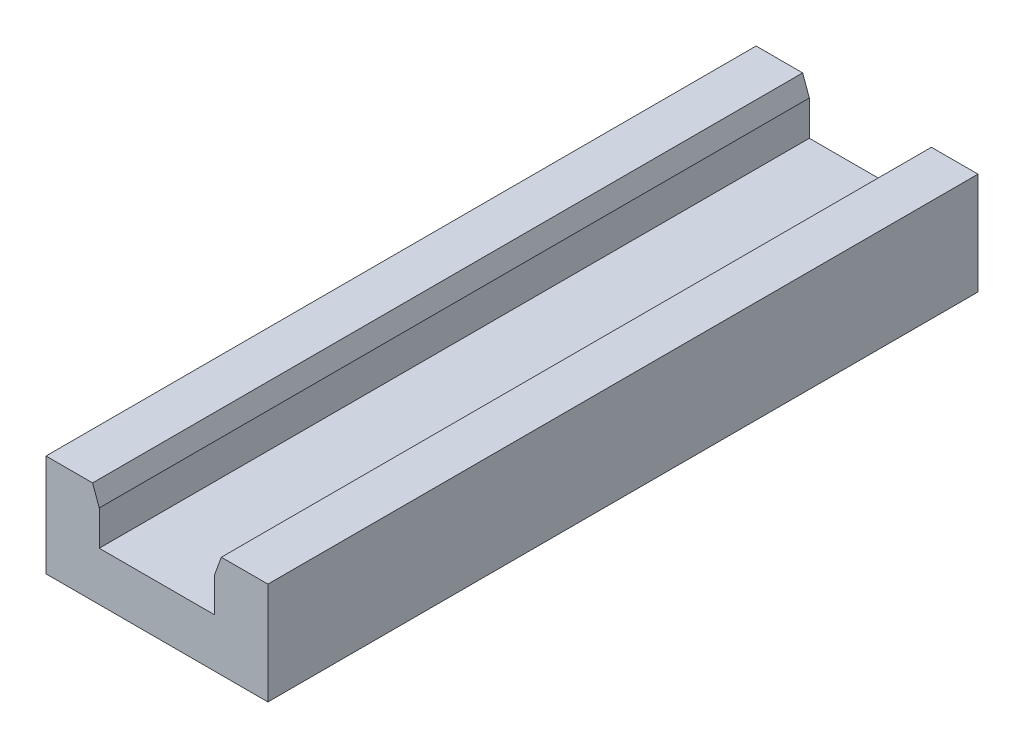
from build123d import *

# Parameters (mm, degrees)
EXTRUSION1_DEPTH = 160


with BuildPart() as part:
    # Esquisse1 → Extrusion1 (new body)
    with BuildSketch(Plane.XY):
        Polygon((38, 19), (12, 19), (12, 26.86014045), (10.49321435, 31), (0, 31), (0, 8), (50, 8), (50, 31), (39.50678565, 31), (38, 26.86014045), align=None)
    extrude(amount=EXTRUSION1_DEPTH)


solid = part.part
